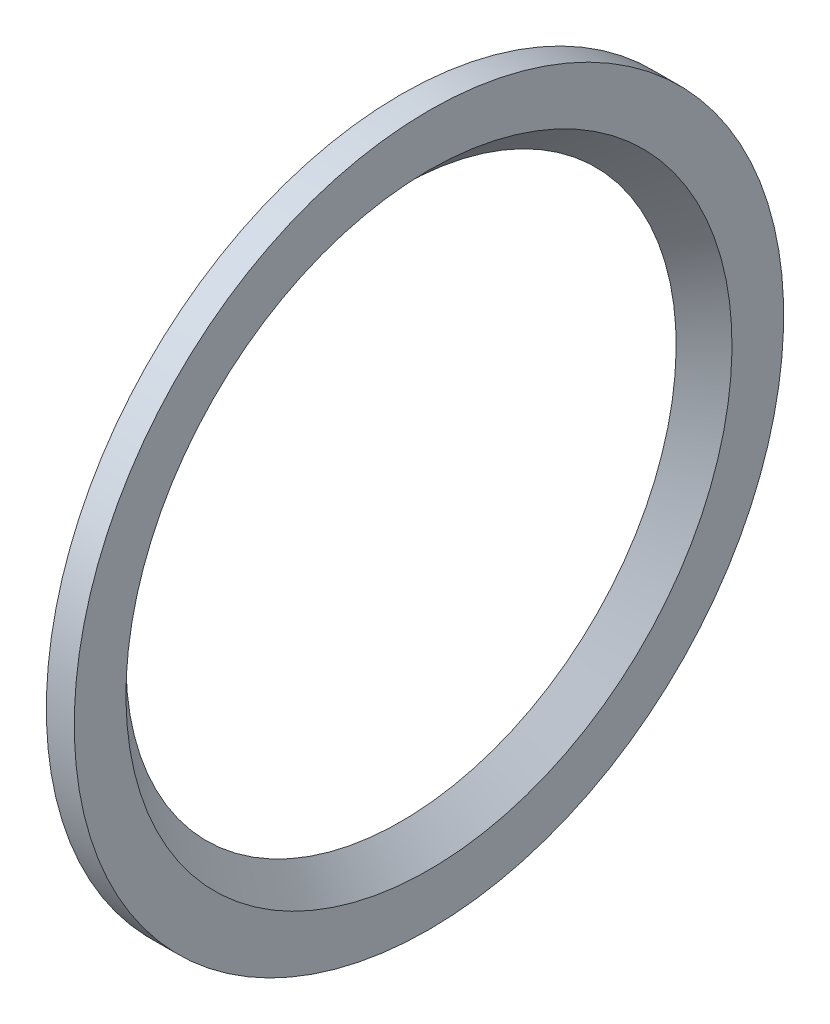
from build123d import *


with BuildPart() as part:
    # Skica1 → Rotovat1 (revolve)
    with BuildSketch(Plane.XY):
        Polygon((-217.05, -19.7), (-217.05, -25.4), (-215.05, -25.4), (-215.05, -21.7), align=None)
    revolve(axis=Axis((-67.482261058, 0, 0), (-1, 0, 0)))


solid = part.part
